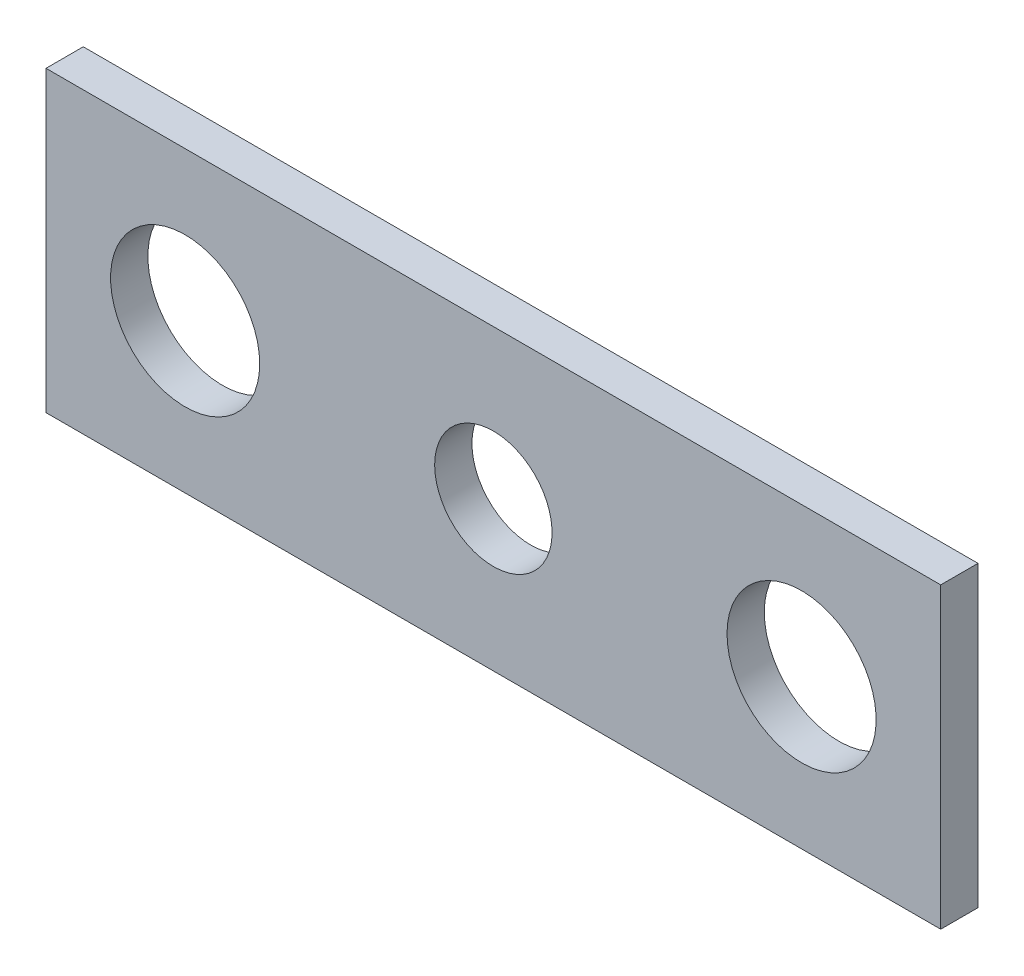
from build123d import *

# Parameters (mm, degrees)
SKETCH1_W           = 152.4
SKETCH1_H           = 50.8
BOSS_EXTRUDE1_DEPTH = 6.35
SKETCH2_R           = 12.7
SKETCH2_R_2         = 10
CUT_EXTRUDE1_DEPTH  = 6.35


with BuildPart() as part:
    # Sketch1 → Boss-Extrude1 (new body)
    with BuildSketch(Plane.XY):
        with Locations((-76.2, 25.4)):
            Rectangle(SKETCH1_W, SKETCH1_H)
    extrude(amount=BOSS_EXTRUDE1_DEPTH)

    # Sketch2 → Cut-Extrude1 (cut)
    with BuildSketch(Plane(origin=(0, 0, 0), x_dir=(-1, 0, 0), z_dir=(0, 0, -1))):
        with Locations((23.7, 25.4)):
            Circle(SKETCH2_R)
        with Locations((76.2, 25.4)):
            Circle(SKETCH2_R_2)
        with Locations((128.7, 25.4)):
            Circle(SKETCH2_R)
    extrude(amount=-CUT_EXTRUDE1_DEPTH, mode=Mode.SUBTRACT)


solid = part.part
